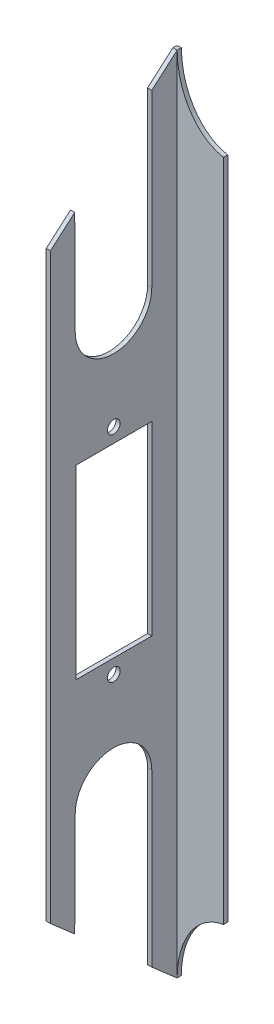
from build123d import *

# Parameters (mm, degrees)
SZKIC1_R                    = 1.5
SZKIC1_W                    = 18
SZKIC1_H                    = 44
DODANIE_WYCI_GNI_CIE1_DEPTH = 1
DODANIE_WYCI_GNI_CIE2_DEPTH = 1
DODANIE_WYCI_GNI_CIE3_DEPTH = 1
ZAOKR_GLENIE2_R             = 0.5
WYTNIJ_WYCI_GNI_CIE1_DEPTH  = 1


with BuildPart() as part:
    # Szkic1 → Dodanie-wyciągnięcie1 (new body)
    with BuildSketch(Plane.ZY.offset(-907.5)):
        with BuildLine():
            Line((1160.348252133, 68.981105632), (1130.348252133, 95.143896329))
            Line((1130.348252133, 95.143896329), (1130.348252133, 25.4))
            ThreePointArc((1130.348252133, 25.4), (1145.348252133, 40.4), (1160.348252133, 25.4))
            Line((1160.348252133, 25.4), (1160.348252133, 68.981105632))
        make_face()
        with BuildLine():
            ThreePointArc((1160.348252133, -25.4), (1145.348252133, -40.4), (1130.348252133, -25.4))
            Line((1130.348252133, -25.4), (1130.348252133, -95.143896329))
            Line((1130.348252133, -95.143896329), (1160.348252133, -68.981105632))
            Line((1160.348252133, -68.981105632), (1160.348252133, -25.4))
        make_face()
        with BuildLine():
            ThreePointArc((1160.348252133, 25.4), (1145.348252133, 40.4), (1130.348252133, 25.4))
            Line((1130.348252133, 25.4), (1130.348252133, -25.4))
            ThreePointArc((1130.348252133, -25.4), (1145.348252133, -40.4), (1160.348252133, -25.4))
            Line((1160.348252133, -25.4), (1160.348252133, 25.4))
        make_face()
        with Locations((1145.348252133, -25.4)):
            Circle(SZKIC1_R, mode=Mode.SUBTRACT)
        with Locations((1145.348252133, 0)):
            Rectangle(SZKIC1_W, SZKIC1_H, mode=Mode.SUBTRACT)
        with Locations((1145.348252133, 25.4)):
            Circle(SZKIC1_R, mode=Mode.SUBTRACT)
    extrude(amount=DODANIE_WYCI_GNI_CIE1_DEPTH)



with BuildPart() as body_2:
    # Szkic6 → Dodanie-wyciągnięcie2 (new body)
    with BuildSketch(Plane(origin=(0, 0, 1130.348252133), x_dir=(-1, 0, 0), z_dir=(0, 0, -1))):
        with BuildLine():
            Line((-907.5, 95.143896329), (-907.5, -95.143896329))
            add(Edge.make_bspline(
                [(-907.5, -95.143896329), (-907.5, -85.342796857), (-912.688679245, -79.610078298), (-918.5, -78.678049216)],
                knots=[0.75, 0.75, 0.75, 0.75, 0.971601315, 0.971601315, 0.971601315, 0.971601315], degree=3, weights=[0.5, 0.5, 0.630952381, 0.892857143]))
            Line((-918.5, -78.678049216), (-918.5, 78.678049216))
            add(Edge.make_bspline(
                [(-918.5, 78.678049216), (-912.688679245, 79.610078298), (-907.5, 85.342796857), (-907.5, 95.143896329)],
                knots=[0.528398685, 0.528398685, 0.528398685, 0.528398685, 0.75, 0.75, 0.75, 0.75], degree=3, weights=[0.892857143, 0.630952381, 0.5, 0.5]))
        make_face()
    extrude(amount=DODANIE_WYCI_GNI_CIE2_DEPTH)


with BuildPart() as part_1:
    add(part.part)

    add(body_2.part)  # Dodanie-wyciągnięcie3 merges body 2
    # Szkic7 → Dodanie-wyciągnięcie3 (add)
    with BuildSketch(Plane.ZY.offset(-907.5)):
        Polygon((1129.348252133, -95.143896329), (1129.348252133, 94.307952804), (1129.348252133, 95.143896329), (1130.348252133, 95.143896329), (1130.348252133, -95.143896329), align=None)
    extrude(amount=DODANIE_WYCI_GNI_CIE3_DEPTH)

    # Zaokrąglenie2
    zaokr_glenie2_edges = [part_1.edges().sort_by_distance(p)[0] for p in [
        (906.5, 0, 1129.348252133),
    ]]
    fillet(zaokr_glenie2_edges, radius=ZAOKR_GLENIE2_R)

    # Szkic8 → Wytnij-wyciągnięcie1 (cut)
    with BuildSketch(Plane.ZY.offset(-906.5)):
        with BuildLine():
            ThreePointArc((1145.389561405, 40.399943118), (1151.80100132, 43.031096304), (1154.480703078, 49.422397217))
            Line((1154.480703078, 49.422397217), (1154.599387747, 73.994650155))
            Line((1154.599387747, 73.994650155), (1136.348252133, 89.91133819))
            Line((1136.348252133, 89.91133819), (1136.348252133, 49.466187083))
            ThreePointArc((1136.348252133, 49.466187083), (1138.99488175, 43.064194171), (1145.389561405, 40.399943118))
        make_face()
    wytnij_wyci_gni_cie1 = extrude(amount=-WYTNIJ_WYCI_GNI_CIE1_DEPTH, mode=Mode.SUBTRACT)

    # Lustro1: Wytnij-wyciągnięcie1 across plane
    add(wytnij_wyci_gni_cie1.mirror(Plane.ZX), mode=Mode.SUBTRACT)


solid = part_1.part
